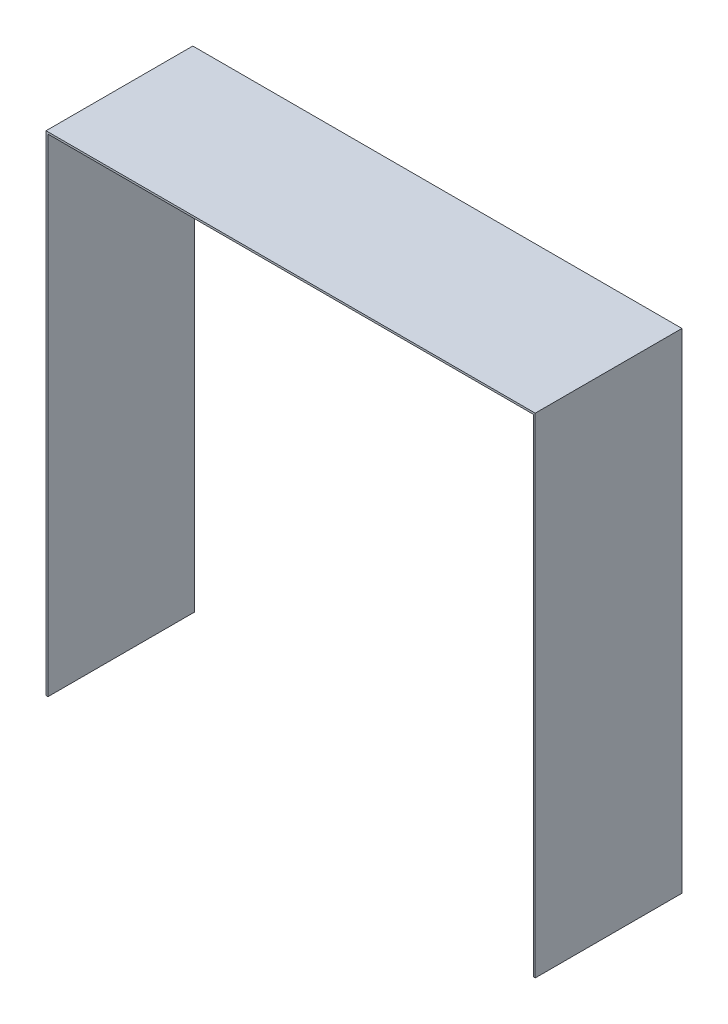
from build123d import *

# Parameters (mm, degrees)
BOSS_EXTRUDE1_DEPTH = 150


with BuildPart() as part:
    # Sketch1 → Boss-Extrude1 (new body)
    with BuildSketch(Plane.XY):
        Polygon((0, 0), (2, 0), (2, 498), (498, 498), (498, 0), (500, 0), (500, 500), (0, 500), align=None)
    extrude(amount=BOSS_EXTRUDE1_DEPTH)


solid = part.part
